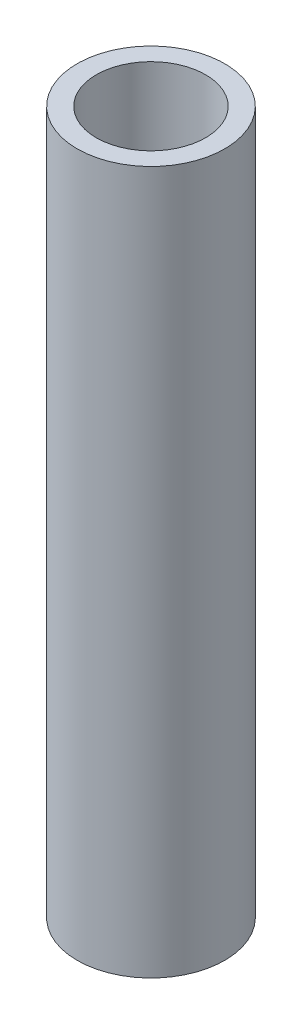
from build123d import *

# Parameters (mm, degrees)
SKETCH1_R           = 10.668
SKETCH1_R_2         = 7.8994
BOSS_EXTRUDE1_DEPTH = 101.6


with BuildPart() as part:
    # Sketch1 → Boss-Extrude1 (new body)
    with BuildSketch(Plane(origin=(0, 0, 0), x_dir=(1, 0, 0), z_dir=(0, 1, 0))):
        Circle(SKETCH1_R)
        Circle(SKETCH1_R_2, mode=Mode.SUBTRACT)
    extrude(amount=BOSS_EXTRUDE1_DEPTH)


solid = part.part
